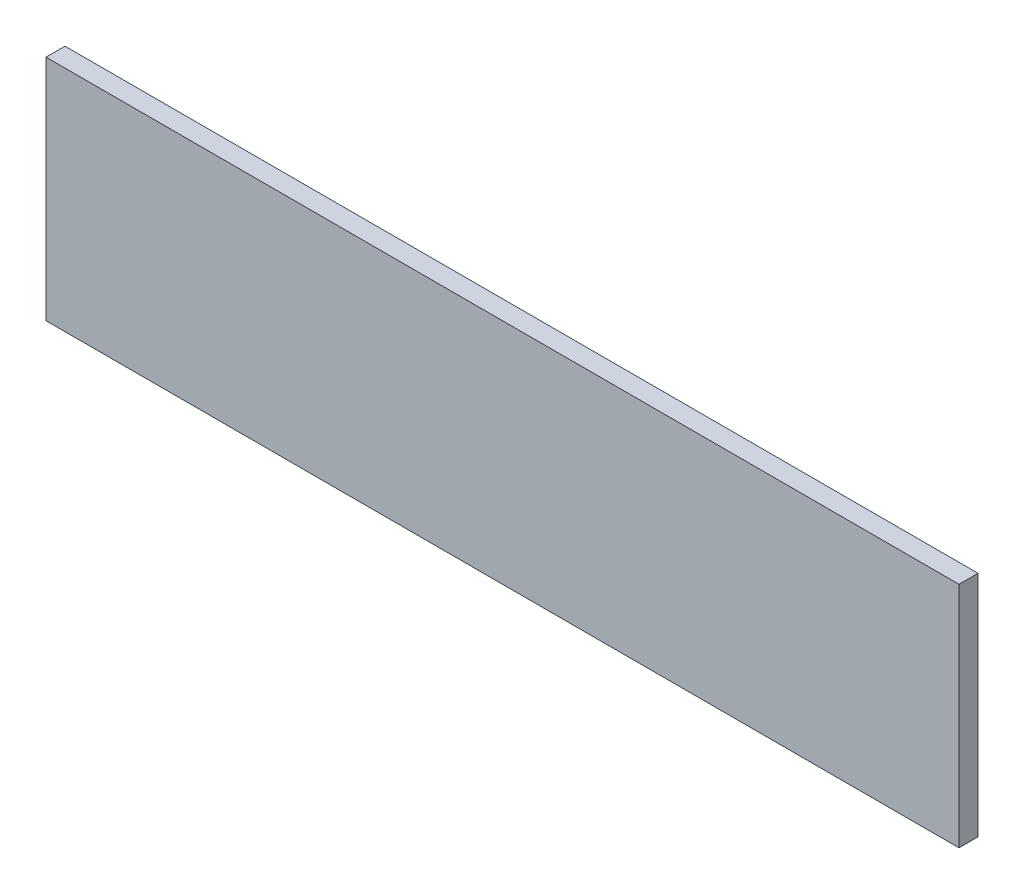
from build123d import *

# Parameters (mm, degrees)
SKETCH1_W           = 6.35
SKETCH1_H           = 76.2
BOSS_EXTRUDE1_DEPTH = 304.8


with BuildPart() as part:
    # Sketch1 → Boss-Extrude1 (new body)
    with BuildSketch(Plane(origin=(0, 0, 0), x_dir=(0, 0, -1), z_dir=(1, 0, 0))):
        Rectangle(SKETCH1_W, SKETCH1_H)
    extrude(amount=BOSS_EXTRUDE1_DEPTH)


solid = part.part
